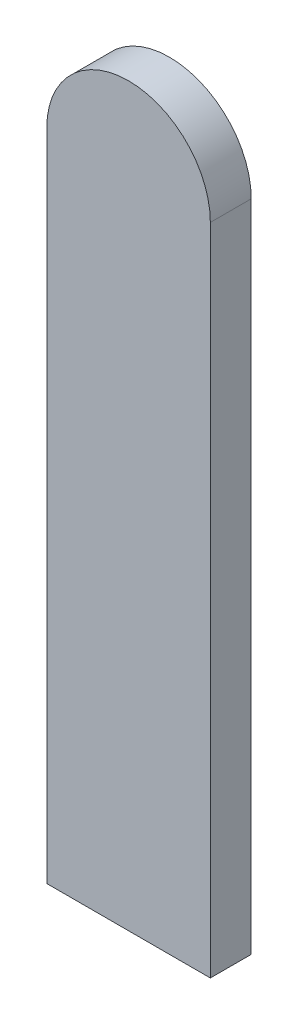
from build123d import *

# Parameters (mm, degrees)
BOSS_EXTRUDE1_DEPTH = 1


with BuildPart() as part:
    # Sketch1 → Boss-Extrude1 (new body)
    with BuildSketch(Plane.XY):
        with BuildLine():
            Line((0, 0), (-4, 0))
            Line((-4, 0), (-4, 16))
            ThreePointArc((-4, 16), (-2, 18), (0, 16))
            Line((0, 16), (0, 0))
        make_face()
    extrude(amount=BOSS_EXTRUDE1_DEPTH)


solid = part.part
